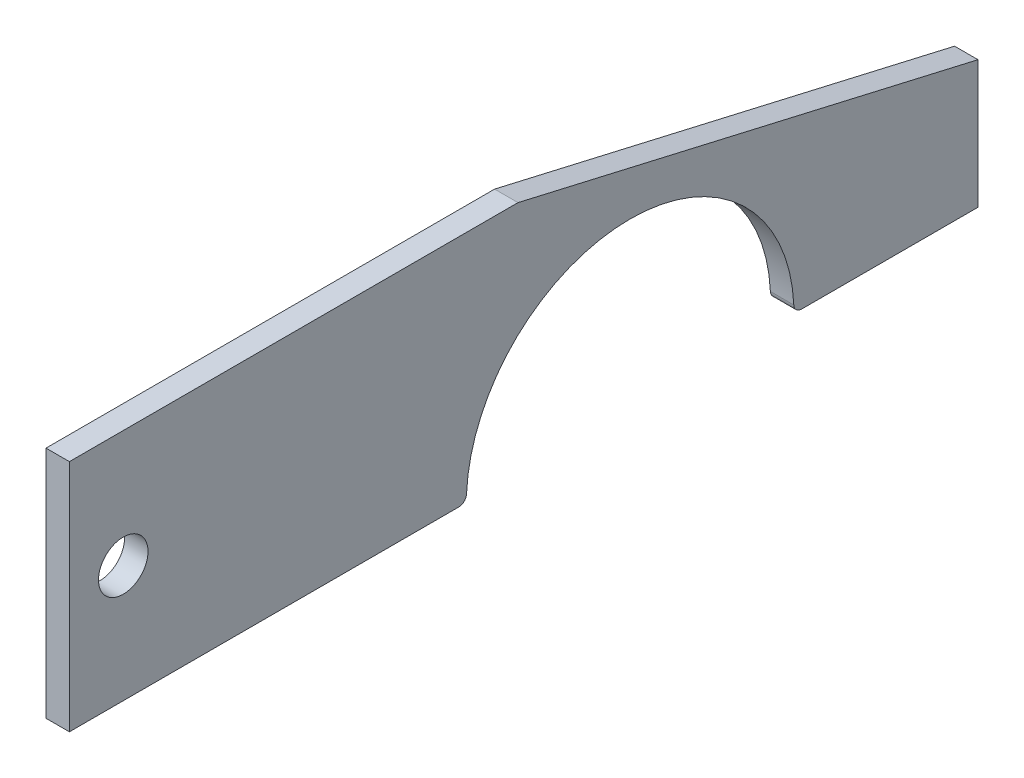
from build123d import *

# Parameters (mm, degrees)
BOSS_EXTRUDE1_DEPTH = 3
SKETCH2_R           = 3.175
CUT_EXTRUDE1_DEPTH  = 4
FILLET2_R           = 1


with BuildPart() as part:
    # Sketch1 → Boss-Extrude1 (new body)
    with BuildSketch(Plane(origin=(0, 0, 0), x_dir=(0, 0, -1), z_dir=(1, 0, 0))):
        with BuildLine():
            Line((0, 0), (57.50407585, 0))
            Line((57.50407585, 0), (116.474786715, -13.615081165))
            Line((116.474786715, -13.615081165), (116.474786715, -30))
            Line((116.474786715, -30), (92.883246032, -30))
            ThreePointArc((92.883246032, -30), (71.883246032, -9), (50.883246032, -30))
            Line((50.883246032, -30), (0, -30))
            Line((0, -30), (0, 0))
        make_face()
    extrude(amount=BOSS_EXTRUDE1_DEPTH)

    # Sketch2 → Cut-Extrude1 (cut, through all)
    with BuildSketch(Plane(origin=(3, 0, 0), x_dir=(0, 0, -1), z_dir=(1, 0, 0))):
        with Locations((6.900903962, -15)):
            Circle(SKETCH2_R)
    extrude(amount=-CUT_EXTRUDE1_DEPTH, mode=Mode.SUBTRACT)

    # Fillet2
    fillet2_edges = [part.edges().sort_by_distance(p)[0] for p in [
        (1.5, -30, -92.883246032),
        (1.5, -30, -50.883246032),
    ]]
    fillet(fillet2_edges, radius=FILLET2_R)


solid = part.part
